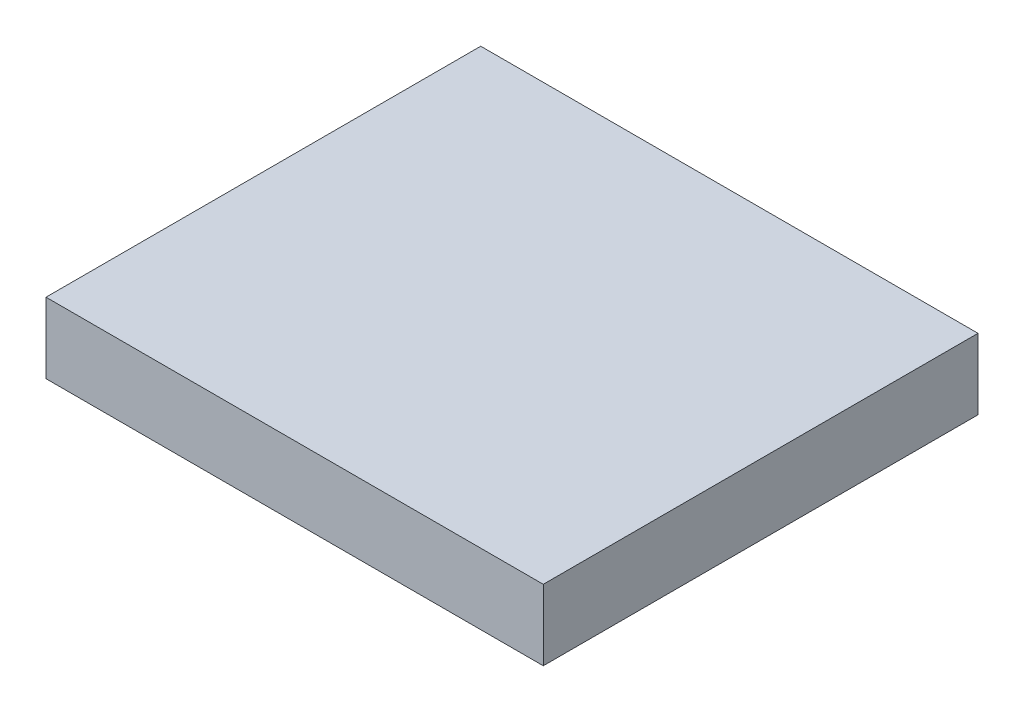
from build123d import *

# Parameters (mm, degrees)
SKETCH1_W           = 20.3962
SKETCH1_H           = 17.8308
BOSS_EXTRUDE1_DEPTH = 2.8956


with BuildPart() as part:
    # Sketch1 → Boss-Extrude1 (new body)
    with BuildSketch(Plane(origin=(0, 0, 0), x_dir=(1, 0, 0), z_dir=(0, 1, 0))):
        Rectangle(SKETCH1_W, SKETCH1_H)
    extrude(amount=BOSS_EXTRUDE1_DEPTH)


solid = part.part
